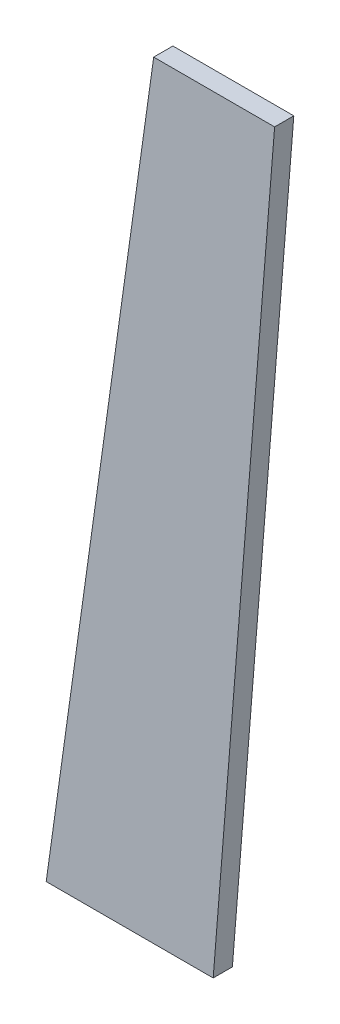
from build123d import *

# Parameters (mm, degrees)
BOSS_EXTRUDE1_DEPTH = 5


with BuildPart() as part:
    # Sketch1 → Boss-Extrude1 (new body)
    with BuildSketch(Plane.XY):
        Polygon((65.5169748, 25), (22.0169748, 25), (50.0169748, 225), (81.5169748, 225), align=None)
    extrude(amount=BOSS_EXTRUDE1_DEPTH)


solid = part.part
